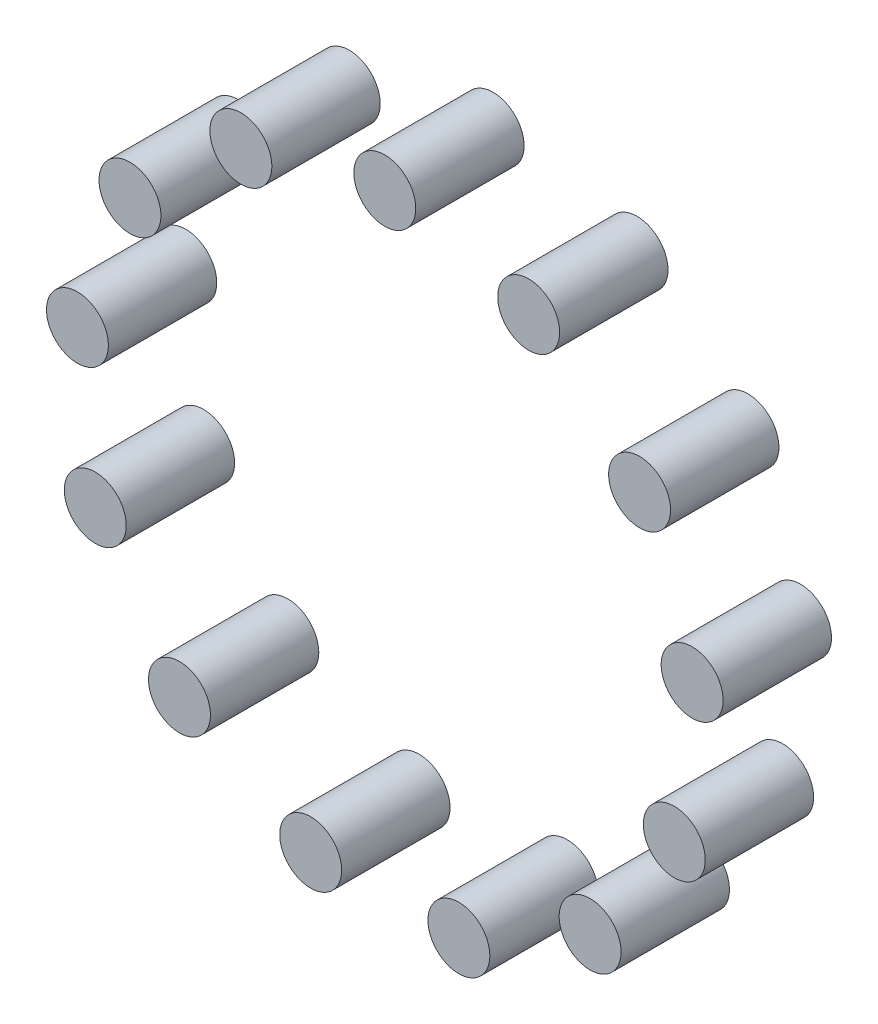
from build123d import *

# Parameters (mm, degrees)
SKETCH1_R              = 4
BOSS_EXTRUDE1_DEPTH    = 14
BOSS_EXTRUDE1_2_DEPTH  = 14
BOSS_EXTRUDE1_3_DEPTH  = 14
BOSS_EXTRUDE1_4_DEPTH  = 14
BOSS_EXTRUDE1_5_DEPTH  = 14
BOSS_EXTRUDE1_6_DEPTH  = 14
BOSS_EXTRUDE1_7_DEPTH  = 14
BOSS_EXTRUDE1_8_DEPTH  = 14
BOSS_EXTRUDE1_9_DEPTH  = 14
BOSS_EXTRUDE1_10_DEPTH = 14
BOSS_EXTRUDE1_11_DEPTH = 14
BOSS_EXTRUDE1_12_DEPTH = 14
BOSS_EXTRUDE1_13_DEPTH = 14


with BuildPart() as part:
    # Sketch1 → Boss-Extrude1 (new body)
    with BuildSketch(Plane.XY):
        with Locations((0, 40)):
            Circle(SKETCH1_R)
    extrude(amount=BOSS_EXTRUDE1_DEPTH)


with BuildPart() as body_2:
    # Sketch1 → Boss-Extrude1 2 (new body)
    with BuildSketch(Plane.XY):
        with Locations((18.588926882, 35.418241026)):
            Circle(SKETCH1_R)
    extrude(amount=BOSS_EXTRUDE1_2_DEPTH)


with BuildPart() as body_3:
    # Sketch1 → Boss-Extrude1 3 (new body)
    with BuildSketch(Plane.XY):
        with Locations((32.919354636, 22.722589869)):
            Circle(SKETCH1_R)
    extrude(amount=BOSS_EXTRUDE1_3_DEPTH)


with BuildPart() as body_4:
    # Sketch1 → Boss-Extrude1 4 (new body)
    with BuildSketch(Plane.XY):
        with Locations((39.708354964, 4.82146721)):
            Circle(SKETCH1_R)
    extrude(amount=BOSS_EXTRUDE1_4_DEPTH)


with BuildPart() as body_5:
    # Sketch1 → Boss-Extrude1 5 (new body)
    with BuildSketch(Plane.XY):
        with Locations((37.400649707, -14.184195482)):
            Circle(SKETCH1_R)
    extrude(amount=BOSS_EXTRUDE1_5_DEPTH)


with BuildPart() as body_6:
    # Sketch1 → Boss-Extrude1 6 (new body)
    with BuildSketch(Plane.XY):
        with Locations((26.52490633, -29.940429927)):
            Circle(SKETCH1_R)
    extrude(amount=BOSS_EXTRUDE1_6_DEPTH)


with BuildPart() as body_7:
    # Sketch1 → Boss-Extrude1 7 (new body)
    with BuildSketch(Plane.XY):
        with Locations((9.572626572, -38.837672697)):
            Circle(SKETCH1_R)
    extrude(amount=BOSS_EXTRUDE1_7_DEPTH)


with BuildPart() as body_8:
    # Sketch1 → Boss-Extrude1 8 (new body)
    with BuildSketch(Plane.XY):
        with Locations((-9.572626572, -38.837672697)):
            Circle(SKETCH1_R)
    extrude(amount=BOSS_EXTRUDE1_8_DEPTH)


with BuildPart() as body_9:
    # Sketch1 → Boss-Extrude1 9 (new body)
    with BuildSketch(Plane.XY):
        with Locations((-26.52490633, -29.940429927)):
            Circle(SKETCH1_R)
    extrude(amount=BOSS_EXTRUDE1_9_DEPTH)


with BuildPart() as body_10:
    # Sketch1 → Boss-Extrude1 10 (new body)
    with BuildSketch(Plane.XY):
        with Locations((-37.400649707, -14.184195482)):
            Circle(SKETCH1_R)
    extrude(amount=BOSS_EXTRUDE1_10_DEPTH)


with BuildPart() as body_11:
    # Sketch1 → Boss-Extrude1 11 (new body)
    with BuildSketch(Plane.XY):
        with Locations((-39.708354964, 4.82146721)):
            Circle(SKETCH1_R)
    extrude(amount=BOSS_EXTRUDE1_11_DEPTH)


with BuildPart() as body_12:
    # Sketch1 → Boss-Extrude1 12 (new body)
    with BuildSketch(Plane.XY):
        with Locations((-32.919354636, 22.722589869)):
            Circle(SKETCH1_R)
    extrude(amount=BOSS_EXTRUDE1_12_DEPTH)


with BuildPart() as body_13:
    # Sketch1 → Boss-Extrude1 13 (new body)
    with BuildSketch(Plane.XY):
        with Locations((-18.588926882, 35.418241026)):
            Circle(SKETCH1_R)
    extrude(amount=BOSS_EXTRUDE1_13_DEPTH)


solid = Compound([part.part, body_2.part, body_3.part, body_4.part, body_5.part, body_6.part, body_7.part, body_8.part, body_9.part, body_10.part, body_11.part, body_12.part, body_13.part])
